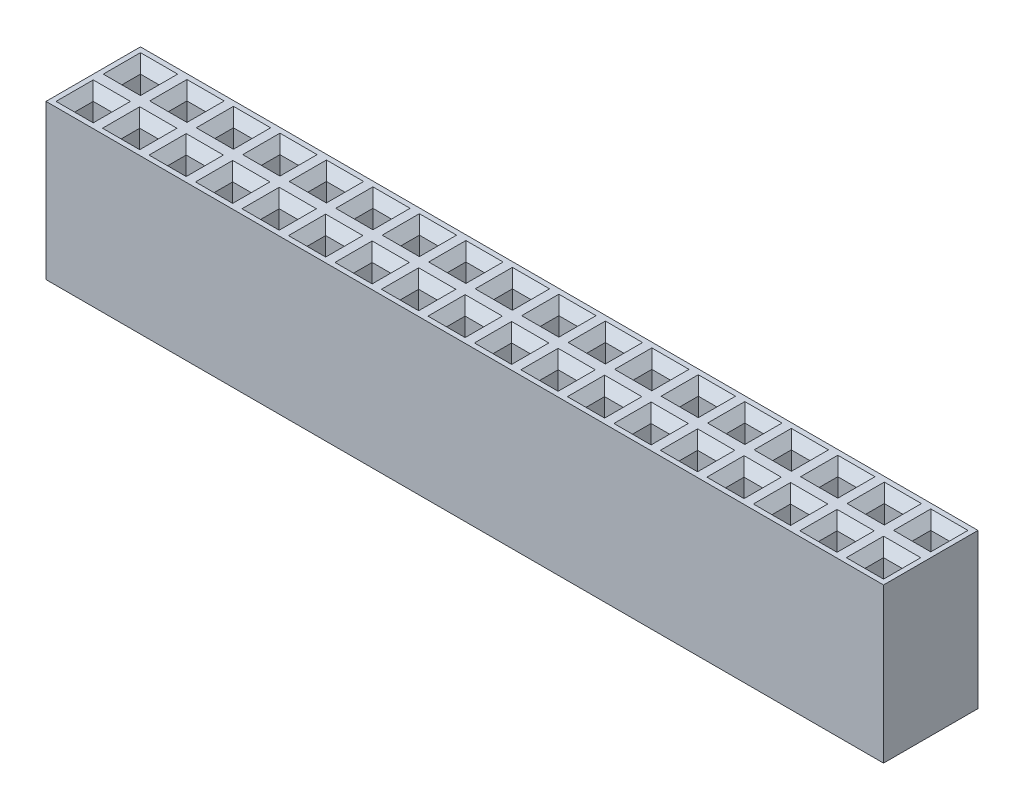
from build123d import *

# Parameters (mm, degrees)
SKETCH1_W                  = 2.54
SKETCH1_H                  = 2.54
BOSS_EXTRUDE1_DEPTH        = 8.3
SKETCH2_W                  = 1
SKETCH2_H                  = 1
CUT_EXTRUDE1_DEPTH         = 4
CHAMFER1_SIZE              = 0.5
LPATTERN1_COUNT            = 18
LPATTERN1_PITCH            = 2.5
LPATTERN1_COUNT_DIR2       = 2
LPATTERN1_PITCH_DIR2       = 2.54
CHAMFER1_OF_LPATTERN1_SIZE = 0.5


with BuildPart() as part:
    # Sketch1 → Boss-Extrude1 (new body)
    with BuildSketch(Plane(origin=(0, 0, 0), x_dir=(1, 0, 0), z_dir=(0, 1, 0))):
        Rectangle(SKETCH1_W, SKETCH1_H)
    boss_extrude1 = extrude(amount=BOSS_EXTRUDE1_DEPTH)

    # Sketch2 → Cut-Extrude1 (cut)
    with BuildSketch(Plane(origin=(0, 8.3, 0), x_dir=(-1, 0, 0), z_dir=(0, 1, 0))):
        Rectangle(SKETCH2_W, SKETCH2_H)
    cut_extrude1 = extrude(amount=-CUT_EXTRUDE1_DEPTH, mode=Mode.SUBTRACT)

    # Chamfer1
    chamfer1_edges = [part.edges().sort_by_distance(p)[0] for p in [
        (0, 8.3, 0.5),
        (0.5, 8.3, 0),
        (0, 8.3, -0.5),
        (-0.5, 8.3, 0),
    ]]
    chamfer(chamfer1_edges, length=CHAMFER1_SIZE)

    # LPattern1: Boss-Extrude1, Cut-Extrude1 18 × 2
    with Locations(*[(i * LPATTERN1_PITCH, 0, -j * LPATTERN1_PITCH_DIR2) for i in range(LPATTERN1_COUNT) for j in range(LPATTERN1_COUNT_DIR2) if (i, j) != (0, 0)]):
        add(boss_extrude1)
        add(cut_extrude1, mode=Mode.SUBTRACT)

    # Chamfer1 of LPattern1
    chamfer1_of_lpattern1_edges = [part.edges().sort_by_distance(p)[0] for p in [
        (0, 8.3, -2.04),
        (0.5, 8.3, -2.54),
        (0, 8.3, -3.04),
        (-0.5, 8.3, -2.54),
        (2.5, 8.3, 0.5),
        (3, 8.3, 0),
        (2.5, 8.3, -0.5),
        (2, 8.3, 0),
        (2.5, 8.3, -2.04),
        (3, 8.3, -2.54),
        (2.5, 8.3, -3.04),
        (2, 8.3, -2.54),
        (5, 8.3, 0.5),
        (5.5, 8.3, 0),
        (5, 8.3, -0.5),
        (4.5, 8.3, 0),
        (5, 8.3, -2.04),
        (5.5, 8.3, -2.54),
        (5, 8.3, -3.04),
        (4.5, 8.3, -2.54),
        (7.5, 8.3, 0.5),
        (8, 8.3, 0),
        (7.5, 8.3, -0.5),
        (7, 8.3, 0),
        (7.5, 8.3, -2.04),
        (8, 8.3, -2.54),
        (7.5, 8.3, -3.04),
        (7, 8.3, -2.54),
        (10, 8.3, 0.5),
        (10.5, 8.3, 0),
        (10, 8.3, -0.5),
        (9.5, 8.3, 0),
        (10, 8.3, -2.04),
        (10.5, 8.3, -2.54),
        (10, 8.3, -3.04),
        (9.5, 8.3, -2.54),
        (12.5, 8.3, 0.5),
        (13, 8.3, 0),
        (12.5, 8.3, -0.5),
        (12, 8.3, 0),
        (12.5, 8.3, -2.04),
        (13, 8.3, -2.54),
        (12.5, 8.3, -3.04),
        (12, 8.3, -2.54),
        (15, 8.3, 0.5),
        (15.5, 8.3, 0),
        (15, 8.3, -0.5),
        (14.5, 8.3, 0),
        (15, 8.3, -2.04),
        (15.5, 8.3, -2.54),
        (15, 8.3, -3.04),
        (14.5, 8.3, -2.54),
        (17.5, 8.3, 0.5),
        (18, 8.3, 0),
        (17.5, 8.3, -0.5),
        (17, 8.3, 0),
        (17.5, 8.3, -2.04),
        (18, 8.3, -2.54),
        (17.5, 8.3, -3.04),
        (17, 8.3, -2.54),
        (20, 8.3, 0.5),
        (20.5, 8.3, 0),
        (20, 8.3, -0.5),
        (19.5, 8.3, 0),
        (20, 8.3, -2.04),
        (20.5, 8.3, -2.54),
        (20, 8.3, -3.04),
        (19.5, 8.3, -2.54),
        (22.5, 8.3, 0.5),
        (23, 8.3, 0),
        (22.5, 8.3, -0.5),
        (22, 8.3, 0),
        (22.5, 8.3, -2.04),
        (23, 8.3, -2.54),
        (22.5, 8.3, -3.04),
        (22, 8.3, -2.54),
        (25, 8.3, 0.5),
        (25.5, 8.3, 0),
        (25, 8.3, -0.5),
        (24.5, 8.3, 0),
        (25, 8.3, -2.04),
        (25.5, 8.3, -2.54),
        (25, 8.3, -3.04),
        (24.5, 8.3, -2.54),
        (27.5, 8.3, 0.5),
        (28, 8.3, 0),
        (27.5, 8.3, -0.5),
        (27, 8.3, 0),
        (27.5, 8.3, -2.04),
        (28, 8.3, -2.54),
        (27.5, 8.3, -3.04),
        (27, 8.3, -2.54),
        (30, 8.3, 0.5),
        (30.5, 8.3, 0),
        (30, 8.3, -0.5),
        (29.5, 8.3, 0),
        (30, 8.3, -2.04),
        (30.5, 8.3, -2.54),
        (30, 8.3, -3.04),
        (29.5, 8.3, -2.54),
        (32.5, 8.3, 0.5),
        (33, 8.3, 0),
        (32.5, 8.3, -0.5),
        (32, 8.3, 0),
        (32.5, 8.3, -2.04),
        (33, 8.3, -2.54),
        (32.5, 8.3, -3.04),
        (32, 8.3, -2.54),
        (35, 8.3, 0.5),
        (35.5, 8.3, 0),
        (35, 8.3, -0.5),
        (34.5, 8.3, 0),
        (35, 8.3, -2.04),
        (35.5, 8.3, -2.54),
        (35, 8.3, -3.04),
        (34.5, 8.3, -2.54),
        (37.5, 8.3, 0.5),
        (38, 8.3, 0),
        (37.5, 8.3, -0.5),
        (37, 8.3, 0),
        (37.5, 8.3, -2.04),
        (38, 8.3, -2.54),
        (37.5, 8.3, -3.04),
        (37, 8.3, -2.54),
        (40, 8.3, 0.5),
        (40.5, 8.3, 0),
        (40, 8.3, -0.5),
        (39.5, 8.3, 0),
        (40, 8.3, -2.04),
        (40.5, 8.3, -2.54),
        (40, 8.3, -3.04),
        (39.5, 8.3, -2.54),
        (42.5, 8.3, 0.5),
        (43, 8.3, 0),
        (42.5, 8.3, -0.5),
        (42, 8.3, 0),
        (42.5, 8.3, -2.04),
        (43, 8.3, -2.54),
        (42.5, 8.3, -3.04),
        (42, 8.3, -2.54),
    ]]
    chamfer(chamfer1_of_lpattern1_edges, length=CHAMFER1_OF_LPATTERN1_SIZE)


solid = part.part
